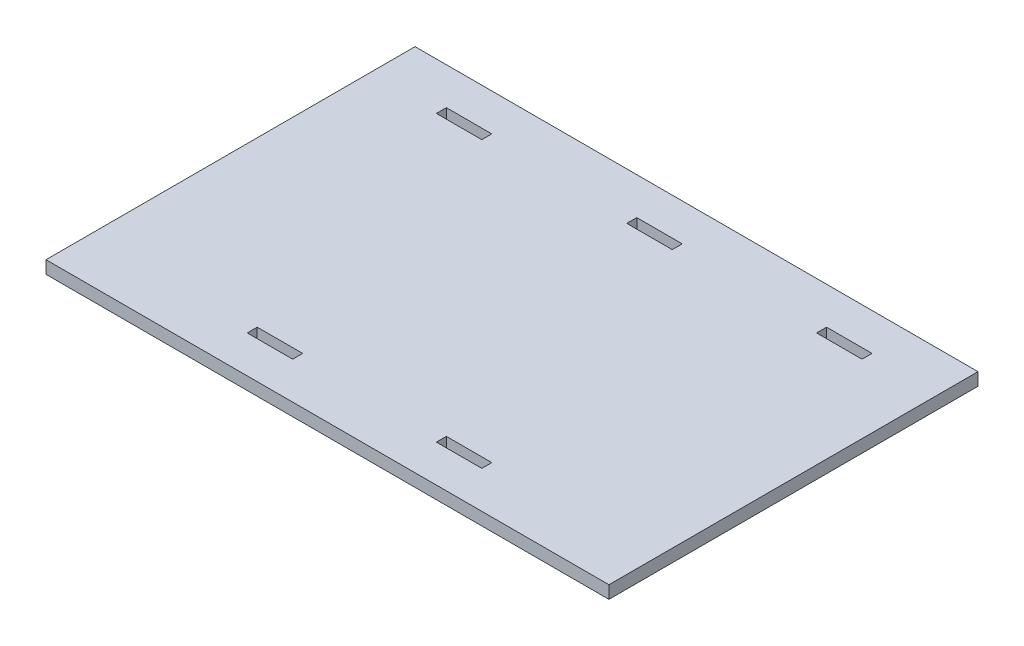
from build123d import *

# Parameters (mm, degrees)
SKETCH2_W               = 563.63
SKETCH2_H               = 369.5
BOSS_EXTRUDE1_DEPTH     = 12.7
SKETCH3_W               = 45.5
SKETCH3_H               = 10
CUT_EXTRUDE2_DEPTH      = 1
CUT_EXTRUDE2_DEPTH_BACK = 13.7


with BuildPart() as part:
    # Sketch2 → Boss-Extrude1 (new body)
    with BuildSketch(Plane(origin=(0, 0, 0), x_dir=(1, 0, 0), z_dir=(0, 1, 0))):
        Rectangle(SKETCH2_W, SKETCH2_H)
    extrude(amount=BOSS_EXTRUDE1_DEPTH)

    # Sketch3 → Cut-Extrude2 (cut, two sides)
    with BuildSketch(Plane(origin=(0, 12.7, 0), x_dir=(1, 0, 0), z_dir=(0, 1, 0))) as cut_extrude2_sk:
        with Locations((-190.485755703, 142.5)):
            Rectangle(SKETCH3_W, SKETCH3_H)
        with Locations((0.170132064, 142.5)):
            Rectangle(SKETCH3_W, SKETCH3_H)
        with Locations((190.170132064, 142.5)):
            Rectangle(SKETCH3_W, SKETCH3_H)
        with Locations((94.514244297, -142.5)):
            Rectangle(SKETCH3_W, SKETCH3_H)
        with Locations((-94.829867936, -142.5)):
            Rectangle(SKETCH3_W, SKETCH3_H)
    extrude(amount=CUT_EXTRUDE2_DEPTH, mode=Mode.SUBTRACT)
    extrude(cut_extrude2_sk.sketch, amount=-CUT_EXTRUDE2_DEPTH_BACK, mode=Mode.SUBTRACT)


solid = part.part
